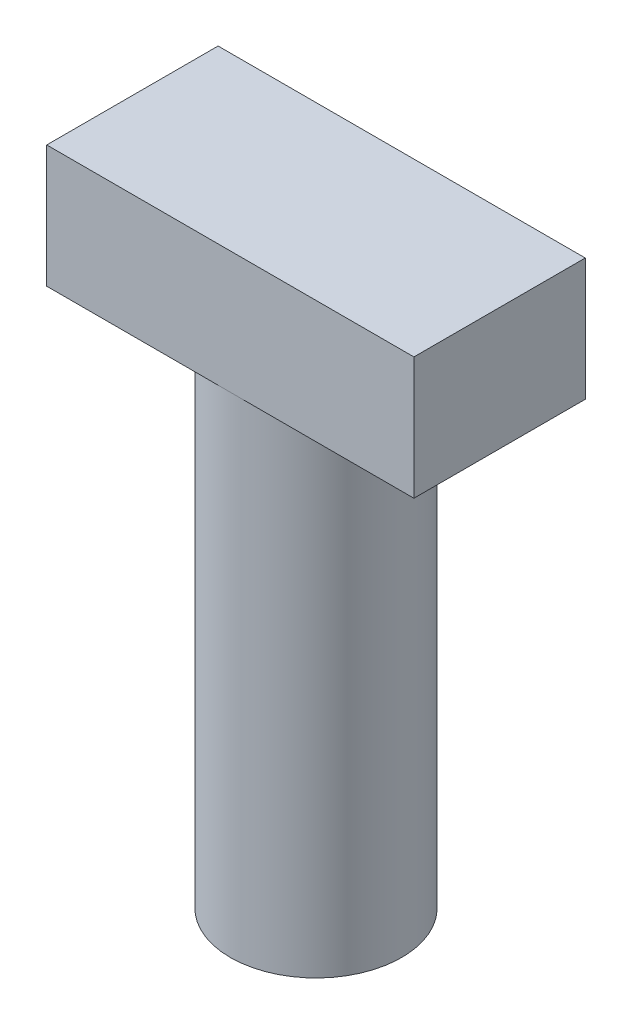
from build123d import *

# Parameters (mm, degrees)
SKETCH2_W           = 30
SKETCH2_H           = 14
BOSS_EXTRUDE1_DEPTH = 10
SKETCH3_R           = 7
BOSS_EXTRUDE2_DEPTH = 40


with BuildPart() as part:
    # Sketch2 → Boss-Extrude1 (new body)
    with BuildSketch(Plane(origin=(0, 0, 0), x_dir=(1, 0, 0), z_dir=(0, 1, 0))):
        Rectangle(SKETCH2_W, SKETCH2_H)
    extrude(amount=-BOSS_EXTRUDE1_DEPTH)

    # Sketch3 → Boss-Extrude2 (add)
    with BuildSketch(Plane.XZ.offset(10)):
        Circle(SKETCH3_R)
    extrude(amount=BOSS_EXTRUDE2_DEPTH)


solid = part.part
